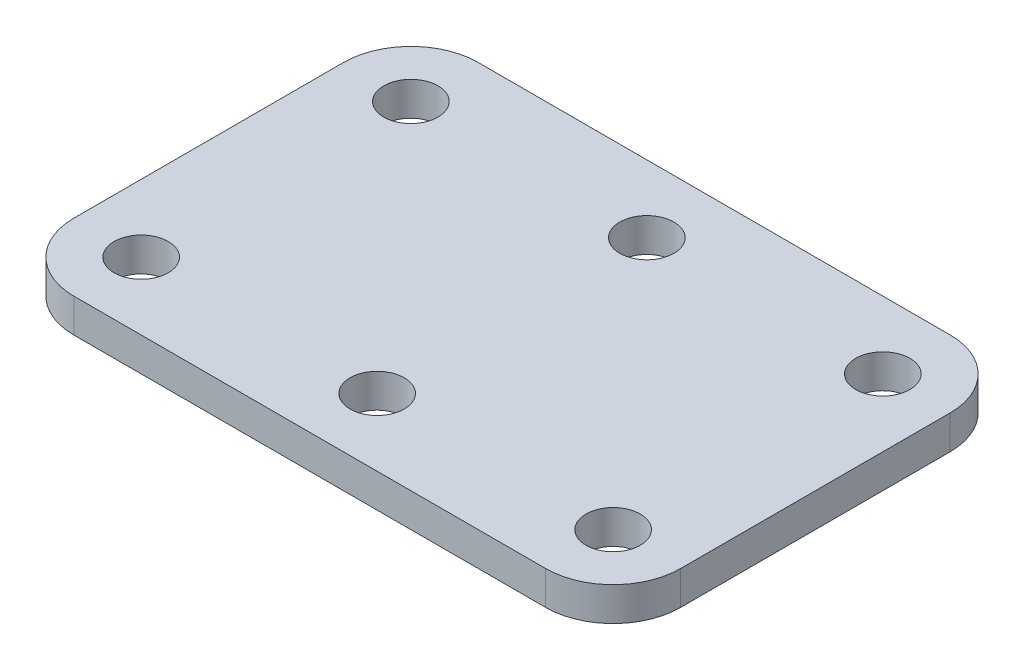
from build123d import *

# Parameters (mm, degrees)
BOSS_EXTRUDE1_DEPTH    = 3.175
F_10_CLEARANCE_HOLE1_D = 5.1054


with BuildPart() as part:
    # Sketch1 → Boss-Extrude1 (new body)
    with BuildSketch(Plane(origin=(0, 0, 0), x_dir=(1, 0, 0), z_dir=(0, 1, 0))):
        with BuildLine():
            Line((22.225, -19.05), (-22.225, -19.05))
            ThreePointArc((-22.225, -19.05), (-26.715128061, -17.190128061), (-28.575, -12.7))
            Line((-28.575, -12.7), (-28.575, 12.7))
            ThreePointArc((-28.575, 12.7), (-26.715128061, 17.190128061), (-22.225, 19.05))
            Line((-22.225, 19.05), (22.225, 19.05))
            ThreePointArc((22.225, 19.05), (26.715128061, 17.190128061), (28.575, 12.7))
            Line((28.575, 12.7), (28.575, -12.7))
            ThreePointArc((28.575, -12.7), (26.715128061, -17.190128061), (22.225, -19.05))
        make_face()
    extrude(amount=BOSS_EXTRUDE1_DEPTH)

    # #10 Clearance Hole1 (through all)
    with Locations(Plane(origin=(0, 3.175, 0), x_dir=(1, 0, 0), z_dir=(0, 1, 0))):
        with Locations((-22.225, 12.7), (0, 12.7), (22.225, 12.7), (0, -12.7), (22.225, -12.7), (-22.225, -12.7)):
            Hole(F_10_CLEARANCE_HOLE1_D / 2)


solid = part.part
